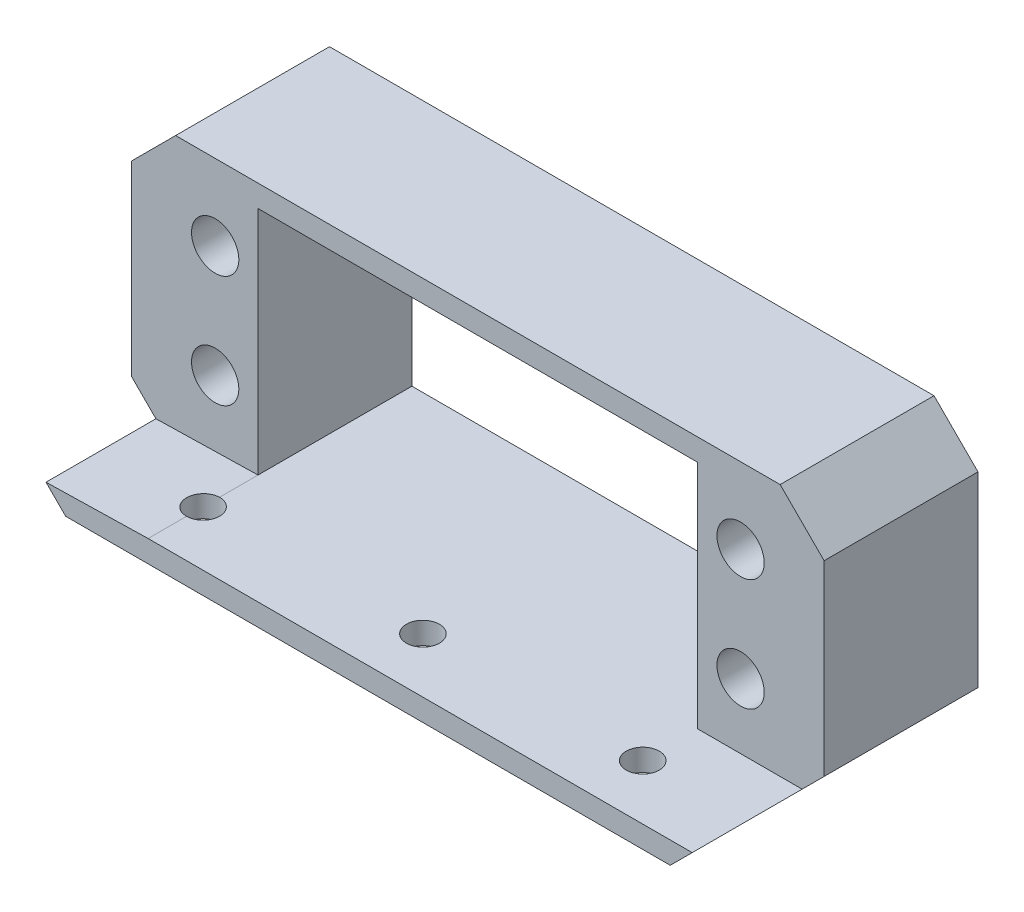
from build123d import *

# Parameters (mm, degrees)
SKETCH1_W           = 40
SKETCH1_H           = 21
BOSS_EXTRUDE1_DEPTH = 14
SKETCH2_R           = 2.15
CUT_EXTRUDE1_DEPTH  = 15
BOSS_EXTRUDE2_DEPTH = 10
SKETCH4_R           = 1.5
CUT_EXTRUDE3_DEPTH  = 26


with BuildPart() as part:
    # Sketch1 → Boss-Extrude1 (new body)
    with BuildSketch(Plane.XY):
        Polygon((-27.5, 12.5), (-31.5, 8.5), (-31.5, -8.5), (-27.5, -12.5), (27.5, -12.5), (31.5, -8.5), (31.5, 8.5), (27.5, 12.5), align=None)
        Rectangle(SKETCH1_W, SKETCH1_H, mode=Mode.SUBTRACT)
    extrude(amount=BOSS_EXTRUDE1_DEPTH)

    # Sketch2 → Cut-Extrude1 (cut, through all)
    with BuildSketch(Plane(origin=(0, 0, 0), x_dir=(-1, 0, 0), z_dir=(0, 0, -1))):
        with Locations((-23.9, 5.6)):
            Circle(SKETCH2_R)
        with Locations((-23.9, -4.6)):
            Circle(SKETCH2_R)
        with Locations((23.9, 5.6)):
            Circle(SKETCH2_R)
        with Locations((23.9, -4.6)):
            Circle(SKETCH2_R)
    extrude(amount=-CUT_EXTRUDE1_DEPTH, mode=Mode.SUBTRACT)

    # Sketch3 → Boss-Extrude2 (add)
    with BuildSketch(Plane.XY.offset(14)):
        Polygon((-27.5, -12.5), (27.5, -12.5), (29.5, -10.5), (20, -10.5), (-20, -10.5), (-29.290326063, -10.709673937), align=None)
    extrude(amount=BOSS_EXTRUDE2_DEPTH)

    # Sketch4 → Cut-Extrude3 (cut, through all)
    with BuildSketch(Plane.XZ.offset(12.5)):
        with Locations((-20, 19)):
            Circle(SKETCH4_R)
        with Locations((20, 19)):
            Circle(SKETCH4_R)
        with Locations((0, 19)):
            Circle(SKETCH4_R)
    extrude(amount=-CUT_EXTRUDE3_DEPTH, mode=Mode.SUBTRACT)


solid = part.part
